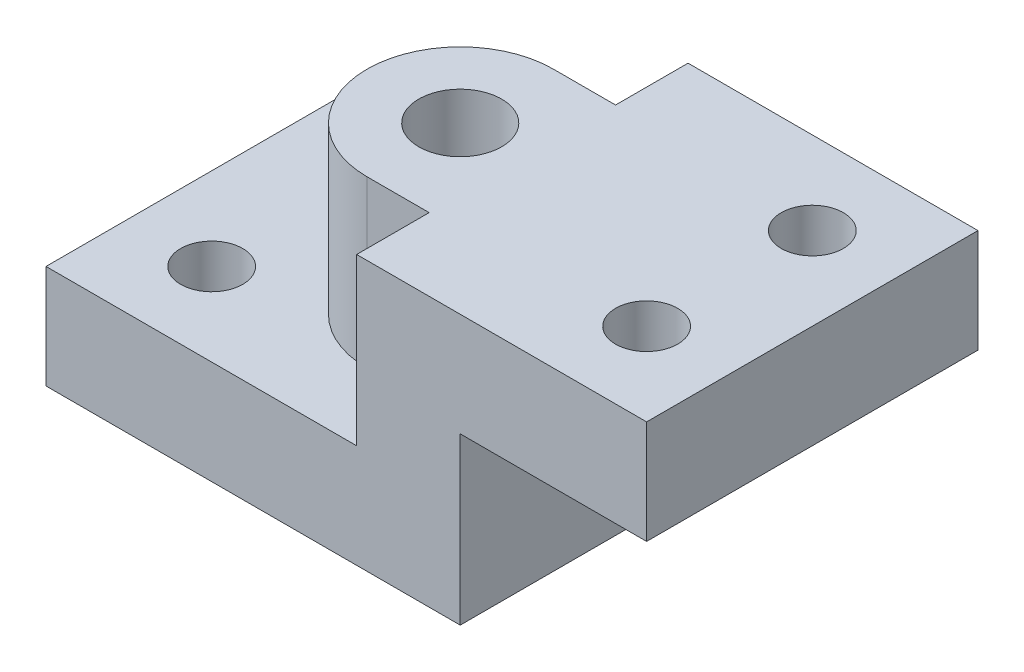
from build123d import *

# Parameters (mm, degrees)
RESSALTO_EXTRUS_O1_DEPTH = 80
RESSALTO_EXTRUS_O2_DEPTH = 80
ESBO_O3_R                = 15
ESBO_O3_R_2              = 20
CORTE_EXTRUS_O2_DEPTH    = 131


with BuildPart() as part:
    # Esboço1 → Ressalto-extrusão1 (new body, symmetric)
    with BuildSketch(Plane.XY):
        Polygon((-110.350506682, 0), (39.649493318, 0), (39.649493318, 80), (179.649493318, 80), (179.649493318, 30), (89.649493318, 30), (89.649493318, -50), (-110.350506682, -50), align=None)
    extrude(amount=RESSALTO_EXTRUS_O1_DEPTH, both=True)

    # Esboço2 → Ressalto-extrusão2 (add)
    with BuildSketch(Plane(origin=(0, 0, 0), x_dir=(1, 0, 0), z_dir=(0, 1, 0))):
        with BuildLine():
            Line((9.649493318, 45), (39.649493318, 45))
            Line((39.649493318, 45), (39.649493318, -45))
            Line((39.649493318, -45), (9.649493318, -45))
            ThreePointArc((9.649493318, -45), (-35.350506682, 0), (9.649493318, 45))
        make_face()
    extrude(amount=RESSALTO_EXTRUS_O2_DEPTH)

    # Esboço3 → Corte-extrusão2 (cut, through all)
    with BuildSketch(Plane(origin=(0, 80, 0), x_dir=(1, 0, 0), z_dir=(0, 1, 0))):
        with Locations((-70.350506682, 40)):
            Circle(ESBO_O3_R)
        with Locations((139.649493318, 40)):
            Circle(ESBO_O3_R)
        with Locations((139.649493318, -40)):
            Circle(ESBO_O3_R)
        with Locations((-70.350506682, -40)):
            Circle(ESBO_O3_R)
        with Locations((9.649493318, 0)):
            Circle(ESBO_O3_R_2)
    extrude(amount=-CORTE_EXTRUS_O2_DEPTH, mode=Mode.SUBTRACT)


solid = part.part
